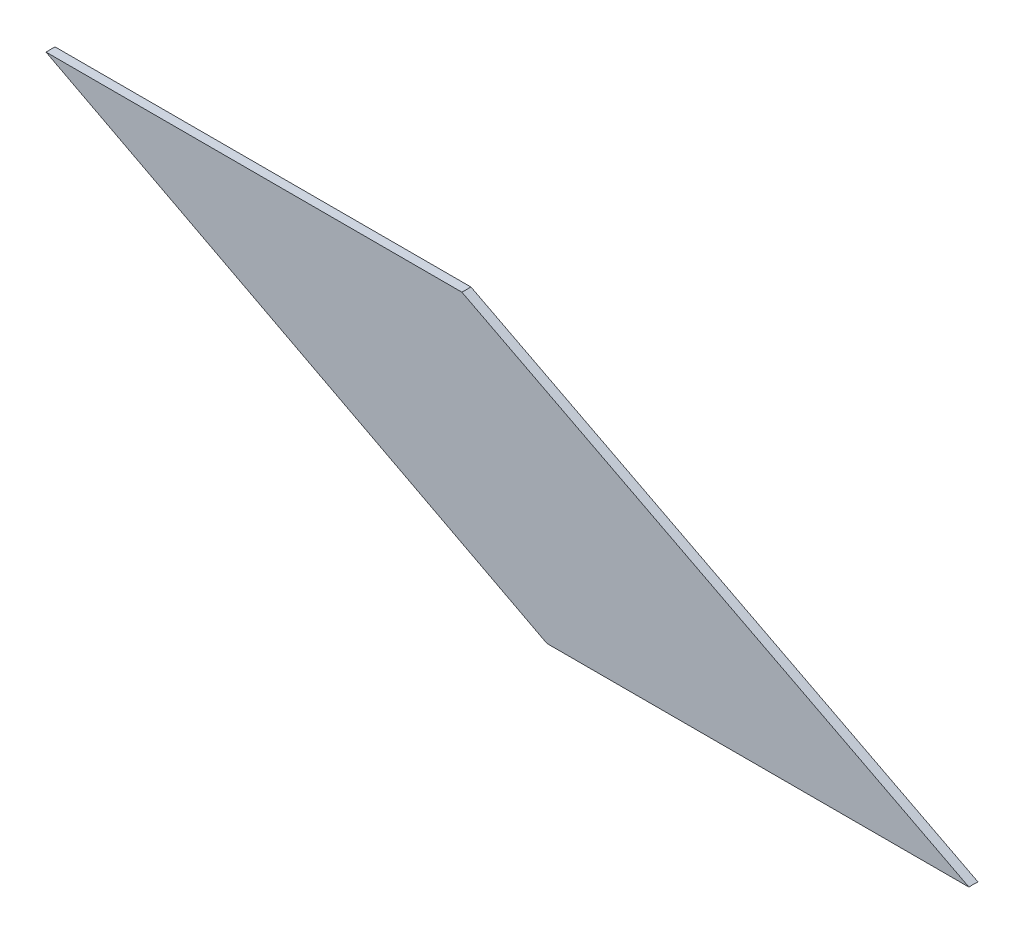
from build123d import *

# Parameters (mm, degrees)
BOSS_EXTRUDE1_DEPTH     = 0.5
SKETCH5_R               = 15.5
CUT_EXTRUDE1_DEPTH      = 1
CUT_EXTRUDE1_DEPTH_BACK = 4930.3219891


with BuildPart() as part:
    # Sketch1 → Boss-Extrude1 (new body, symmetric)
    with BuildSketch(Plane.XY):
        Polygon((-4871.89805391, 14.5), (-4929.3219891, 44.5), (-4883.2219891, 44.5), (-4825.09805391, 14.5), align=None)
    extrude(amount=BOSS_EXTRUDE1_DEPTH, both=True)

    # Sketch5 → Cut-Extrude1 (cut, two sides)
    with BuildSketch(Plane(origin=(0, 0, 0), x_dir=(0, 0, -1), z_dir=(1, 0, 0))) as cut_extrude1_sk:
        Circle(SKETCH5_R)
    extrude(amount=CUT_EXTRUDE1_DEPTH, mode=Mode.SUBTRACT)
    extrude(cut_extrude1_sk.sketch, amount=-CUT_EXTRUDE1_DEPTH_BACK, mode=Mode.SUBTRACT)


solid = part.part
